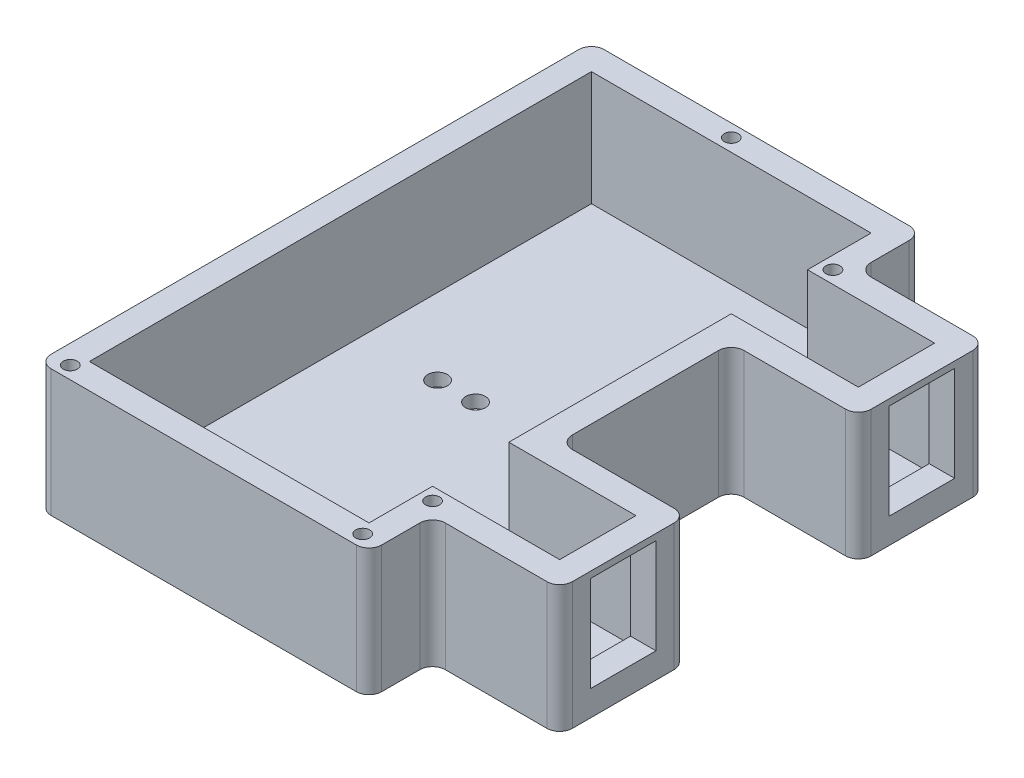
from build123d import *

# Parameters (mm, degrees)
BOSS_EXTRUDE1_DEPTH = 20
SKETCH2_W           = 44
SKETCH2_H           = 79
CUT_EXTRUDE1_DEPTH  = 18
SKETCH3_W           = 20
SKETCH3_H           = 12
CUT_EXTRUDE2_DEPTH  = 18
SKETCH4_R           = 1.1
CUT_EXTRUDE3_DEPTH  = 10
SKETCH5_R           = 1.1
CUT_EXTRUDE4_DEPTH  = 10
SKETCH6_W           = 10.3
SKETCH6_H           = 15
CUT_EXTRUDE5_DEPTH  = 6
SKETCH7_R           = 1.55
CUT_EXTRUDE6_DEPTH  = 6
FILLET1_R           = 2


with BuildPart() as part:
    # Sketch1 → Boss-Extrude1 (new body)
    with BuildSketch(Plane(origin=(0, 0, 0), x_dir=(1, 0, 0), z_dir=(0, 1, 0))):
        Polygon((53.327223789, 77.96478334), (53.327223789, 87.96478334), (1.327223789, 87.96478334), (1.327223789, 0.96478334), (53.327223789, 0.96478334), (53.327223789, 10.96478334), (73.327223789, 10.96478334), (73.327223789, 30.96478334), (53.327223789, 30.96478334), (53.327223789, 57.96478334), (73.327223789, 57.96478334), (73.327223789, 77.96478334), align=None)
    extrude(amount=BOSS_EXTRUDE1_DEPTH)

    # Sketch2 → Cut-Extrude1 (cut)
    with BuildSketch(Plane(origin=(0, 20, 0), x_dir=(1, 0, 0), z_dir=(0, 1, 0))):
        with Locations((27.327223789, 44.46478334)):
            Rectangle(SKETCH2_W, SKETCH2_H)
    extrude(amount=-CUT_EXTRUDE1_DEPTH, mode=Mode.SUBTRACT)

    # Sketch3 → Cut-Extrude2 (cut)
    with BuildSketch(Plane(origin=(0, 20, 0), x_dir=(1, 0, 0), z_dir=(0, 1, 0))):
        with Locations((59.327223789, 67.96478334)):
            Rectangle(SKETCH3_W, SKETCH3_H)
        with Locations((59.327223789, 20.96478334)):
            Rectangle(SKETCH3_W, SKETCH3_H)
    extrude(amount=-CUT_EXTRUDE2_DEPTH, mode=Mode.SUBTRACT)

    # Sketch4 → Cut-Extrude3 (cut)
    with BuildSketch(Plane(origin=(0, 20, 0), x_dir=(1, 0, 0), z_dir=(0, 1, 0))):
        with Locations((4.327223789, 2.96478334)):
            Circle(SKETCH4_R)
        with Locations((50.327223789, 2.96478334)):
            Circle(SKETCH4_R)
        with Locations((25.327223789, 85.96478334)):
            Circle(SKETCH4_R)
    extrude(amount=-CUT_EXTRUDE3_DEPTH, mode=Mode.SUBTRACT)

    # Sketch5 → Cut-Extrude4 (cut)
    with BuildSketch(Plane(origin=(0, 20, 0), x_dir=(1, 0, 0), z_dir=(0, 1, 0))):
        with Locations((51.327223789, 12.96478334)):
            Circle(SKETCH5_R)
        with Locations((51.327223789, 75.96478334)):
            Circle(SKETCH5_R)
    extrude(amount=-CUT_EXTRUDE4_DEPTH, mode=Mode.SUBTRACT)

    # Sketch6 → Cut-Extrude5 (cut)
    with BuildSketch(Plane(origin=(73.327223789, 0, 0), x_dir=(0, 0, -1), z_dir=(1, 0, 0))):
        with Locations((67.96478334, 11.5)):
            Rectangle(SKETCH6_W, SKETCH6_H)
        with Locations((20.96478334, 11.5)):
            Rectangle(SKETCH6_W, SKETCH6_H)
    extrude(amount=-CUT_EXTRUDE5_DEPTH, mode=Mode.SUBTRACT)

    # Sketch7 → Cut-Extrude6 (cut)
    with BuildSketch(Plane(origin=(0, 2, 0), x_dir=(1, 0, 0), z_dir=(0, 1, 0))):
        with Locations((45.297223789, 47.81478334)):
            Circle(SKETCH7_R)
        with Locations((23.237223789, 47.81478334)):
            Circle(SKETCH7_R)
        with Locations((39.327223789, 47.81478334)):
            Circle(SKETCH7_R)
        with Locations((17.267223789, 47.81478334)):
            Circle(SKETCH7_R)
    extrude(amount=-CUT_EXTRUDE6_DEPTH, mode=Mode.SUBTRACT)

    # Fillet1
    fillet1_edges = [part.edges().sort_by_distance(p)[0] for p in [
        (1.327223789, 10, -87.96478334),
        (53.327223789, 10, -87.96478334),
        (53.327223789, 10, -77.96478334),
        (73.327223789, 10, -77.96478334),
        (73.327223789, 10, -57.96478334),
        (53.327223789, 10, -57.96478334),
        (53.327223789, 10, -30.96478334),
        (73.327223789, 10, -30.96478334),
        (73.327223789, 10, -10.96478334),
        (53.327223789, 10, -10.96478334),
        (53.327223789, 10, -0.96478334),
        (1.327223789, 10, -0.96478334),
    ]]
    fillet(fillet1_edges, radius=FILLET1_R)


solid = part.part
